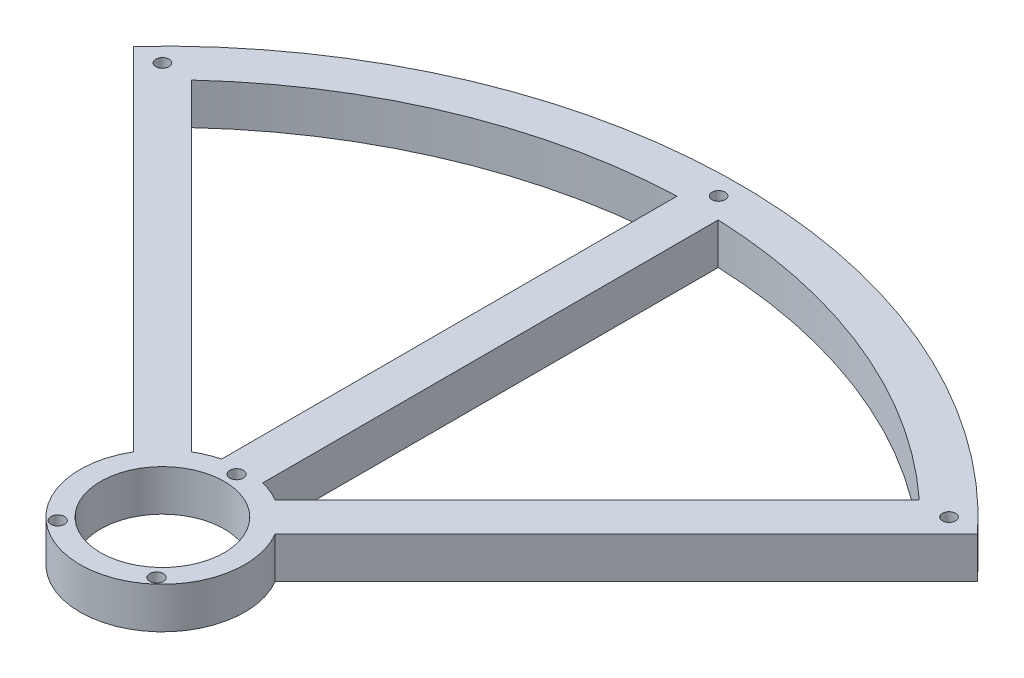
from build123d import *

# Parameters (mm, degrees)
SKETCH_1_R          = 1.65
SKETCH_1_R_2        = 15
EXTRUDE_2_DEPTH     = 10
SKETCH_2_R          = 1.6
CUT_EXTRUDE_1_DEPTH = 11


with BuildPart() as part:
    # 草圖1 → 填料-伸長2 (new body)
    with BuildSketch(Plane(origin=(0, 0, 0), x_dir=(1, 0, 0), z_dir=(0, 1, 0))):
        with BuildLine():
            ThreePointArc((-17.228597844, 10.157530032), (0, -20), (17.228597844, 10.157530032))
            Line((17.228597844, 10.157530032), (102.467328593, 95.396260781))
            ThreePointArc((102.467328593, 95.396260781), (0, 140), (-102.467328593, 95.396260781))
            Line((-102.467328593, 95.396260781), (-17.228597844, 10.157530032))
        make_face()
        with Locations((-12, -13.416407865)):
            Circle(SKETCH_1_R, mode=Mode.SUBTRACT)
        Circle(SKETCH_1_R_2, mode=Mode.SUBTRACT)
        with Locations((0, 18)):
            Circle(SKETCH_1_R, mode=Mode.SUBTRACT)
        with Locations((12, -13.416407865)):
            Circle(SKETCH_1_R, mode=Mode.SUBTRACT)
        with BuildLine():
            ThreePointArc((-88.320331448, 95.39139926), (-49.748846207, 120.104339226), (-5, 129.903810568))
            Line((-5, 129.903810568), (-5, 19.364916731))
            ThreePointArc((-5, 19.364916731), (-7.653668647, 18.47759065), (-10.157530032, 17.228597844))
            Line((-10.157530032, 17.228597844), (-88.320331448, 95.39139926))
        make_face(mode=Mode.SUBTRACT)
        with BuildLine():
            Line((5, 19.364916731), (5, 129.903810568))
            ThreePointArc((5, 129.903810568), (49.748846207, 120.104339226), (88.320331448, 95.39139926))
            Line((88.320331448, 95.39139926), (10.157530032, 17.228597844))
            ThreePointArc((10.157530032, 17.228597844), (7.653668647, 18.47759065), (5, 19.364916731))
        make_face(mode=Mode.SUBTRACT)
    extrude(amount=EXTRUDE_2_DEPTH)

    # 草圖2 → 除料-伸長1 (cut, through all)
    with BuildSketch(Plane(origin=(0, 10, 0), x_dir=(1, 0, 0), z_dir=(0, 1, 0))):
        with Locations((-95.45941546, 95.45941546)):
            Circle(SKETCH_2_R)
        with Locations((0, 135)):
            Circle(SKETCH_2_R)
        with Locations((95.45941546, 95.45941546)):
            Circle(SKETCH_2_R)
    extrude(amount=-CUT_EXTRUDE_1_DEPTH, mode=Mode.SUBTRACT)


solid = part.part
